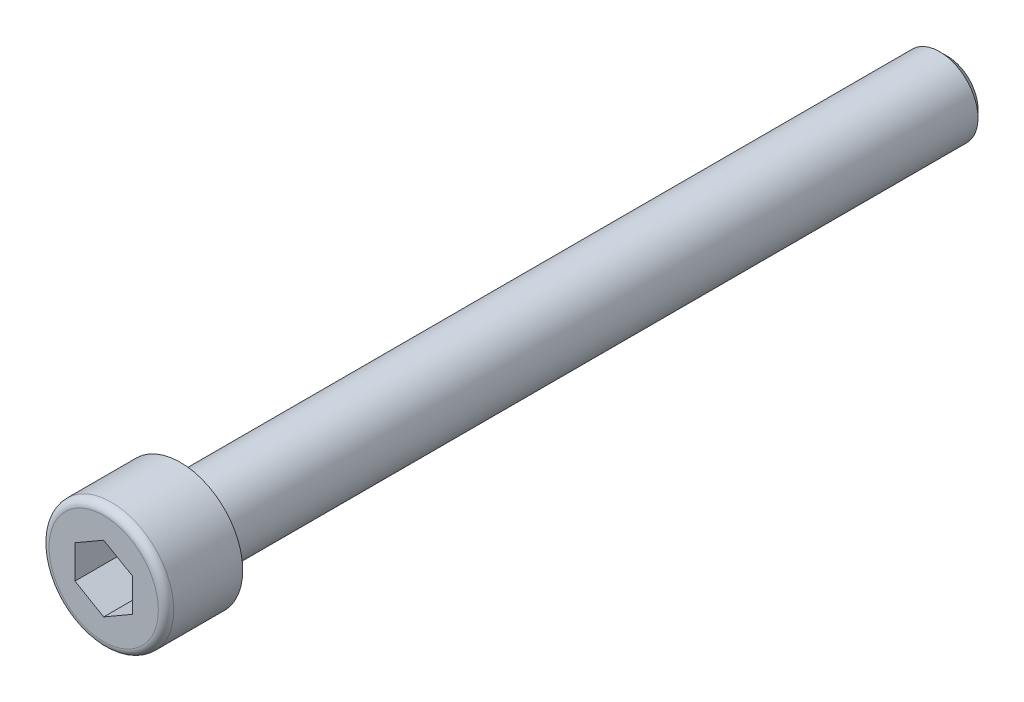
from build123d import *

# Parameters (mm, degrees)
ODEBR_N_PROTA_EN_1_DEPTH = 6


with BuildPart() as part:
    # Skica1 → Základ-Rotační (revolve)
    with BuildSketch(Plane(origin=(0, 0, 0), x_dir=(1, 0, 0), z_dir=(0, 1, 0))):
        with BuildLine():
            Line((0, 80), (0, -8))
            Line((0, -8), (5.7, -8))
            ThreePointArc((5.7, -8), (6.265685425, -7.765685425), (6.5, -7.2))
            Line((6.5, -7.2), (6.5, 0))
            Line((6.5, 0), (4, 0))
            Line((4, 0), (4, 79.2))
            Line((4, 79.2), (3.2, 80))
            Line((3.2, 80), (0, 80))
        make_face()
    revolve(axis=Axis((0, 0, -20.555484665), (0, 0, -1)))

    # Skica2 → Odebrání-Protažení1 (cut)
    with BuildSketch(Plane.XY.offset(8)):
        Polygon((3, -1.732050808), (3, 1.732050808), (0, 3.464101615), (-3, 1.732050808), (-3, -1.732050808), (0, -3.464101615), align=None)
    extrude(amount=-ODEBR_N_PROTA_EN_1_DEPTH, mode=Mode.SUBTRACT)


solid = part.part
